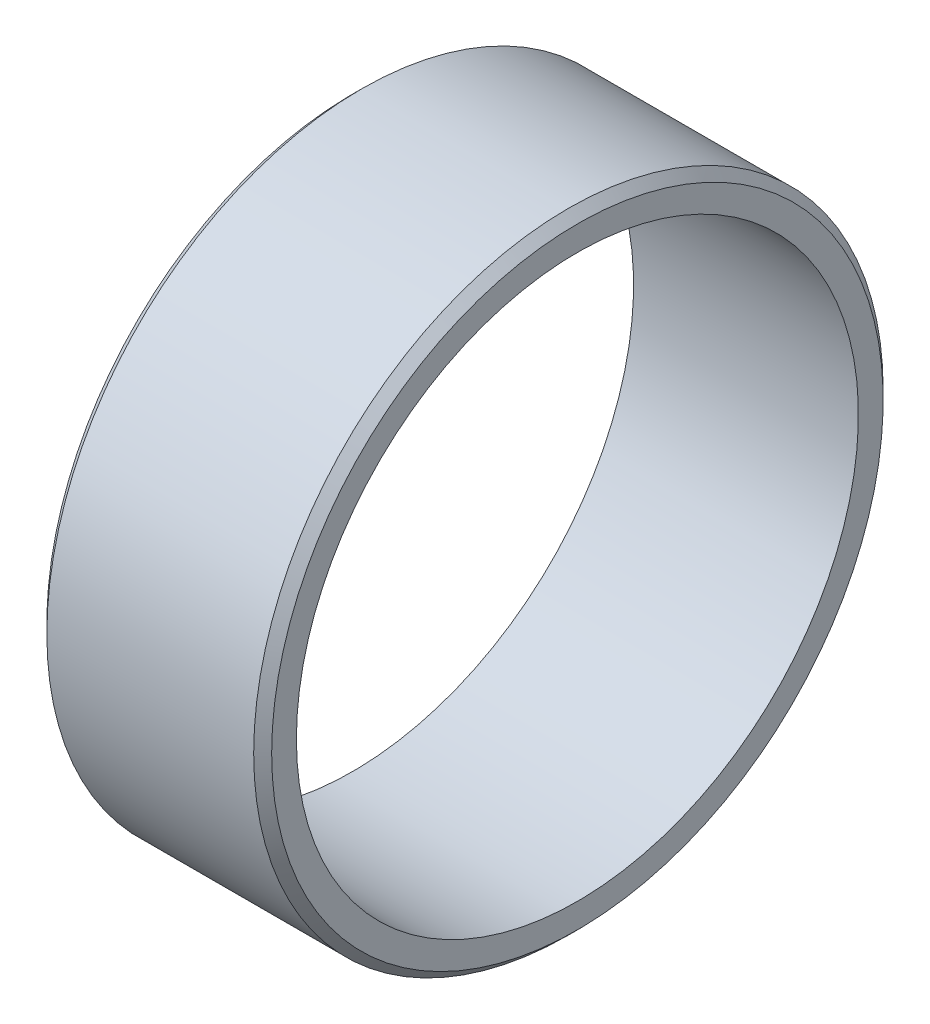
from build123d import *

# Parameters (mm, degrees)
SKETCH1_W     = 10
SKETCH1_H     = 1.5
CHAMFER1_SIZE = 0.4


with BuildPart() as part:
    # Sketch1 → Revolve1 (revolve)
    with BuildSketch(Plane.XY):
        with Locations((0, 13.25)):
            Rectangle(SKETCH1_W, SKETCH1_H)
    revolve(axis=Axis((0, 0, 0), (1, 0, 0)))

    # Chamfer1
    chamfer1_edges = [part.edges().sort_by_distance(p)[0] for p in [
        (-5, -14, 0),
        (5, -14, 0),
    ]]
    chamfer(chamfer1_edges, length=CHAMFER1_SIZE)


solid = part.part
